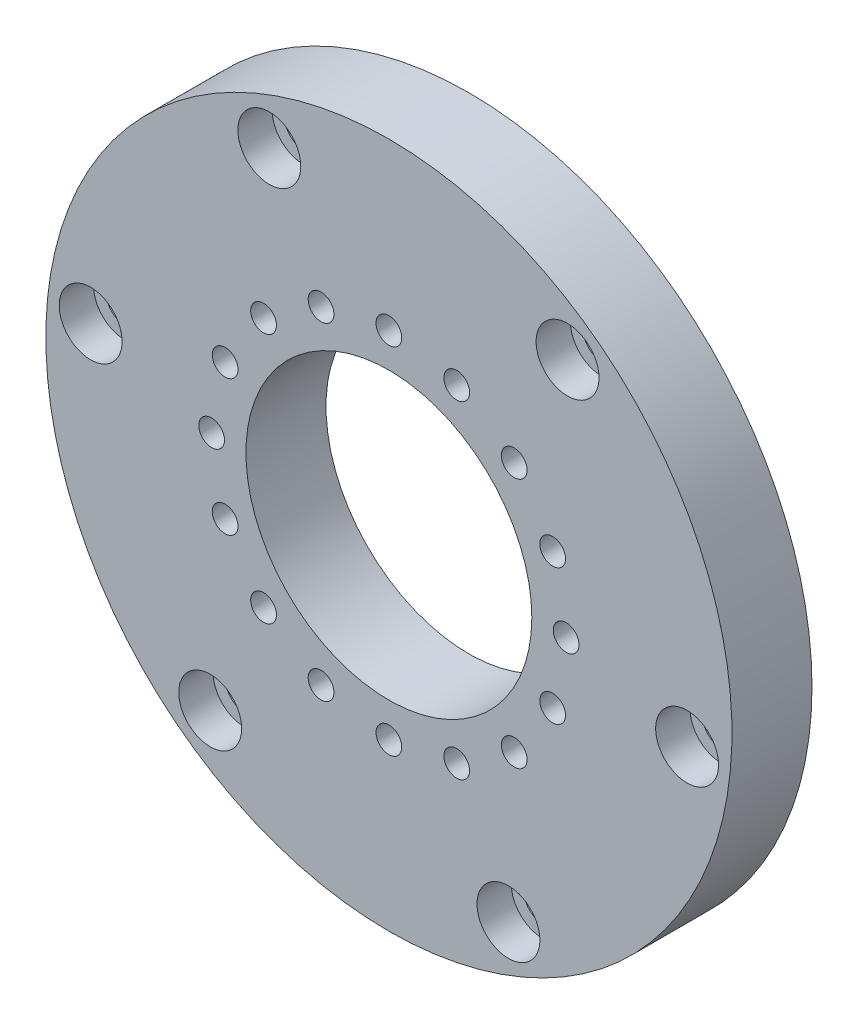
from build123d import *

# Parameters (mm, degrees)
SKETCH_2_R                   = 60
EXTRUDE_1_DEPTH              = 14
HOLE_WIZARD_M6_1_D           = 6.6
HOLE_WIZARD_M6_1_CBORE_D     = 11
HOLE_WIZARD_M6_1_CBORE_DEPTH = 6
PATTERN_CIRCULAR_1_COUNT     = 6
HOLE_WIZARD_M4_1_D           = 4.5
HOLE_WIZARD_M4_1_CBORE_D     = 8
HOLE_WIZARD_M4_1_CBORE_DEPTH = 4
SKETCH_9_R                   = 25
CUT_EXTRUDE_1_DEPTH          = 15


with BuildPart() as part:
    # 草圖2 → 填料-伸長1 (new body)
    with BuildSketch(Plane.XY):
        with Locations((0, -84)):
            Circle(SKETCH_2_R)
    extrude(amount=EXTRUDE_1_DEPTH)

    # M6 承窩頭蓋螺釘的柱孔1 (through all)
    with Locations(Plane.XY.offset(14)):
        with Locations((52.159798329, -89.96702927)):
            hole_wizard_m6_1 = CounterBoreHole(HOLE_WIZARD_M6_1_D / 2, HOLE_WIZARD_M6_1_CBORE_D / 2, HOLE_WIZARD_M6_1_CBORE_DEPTH)

    # 環狀複製排列1: M6 承窩頭蓋螺釘的柱孔1 ×6 about axis
    pattern_circular_1_axis = Axis((0, -84, 0), (0, 0, 1))
    for i in range(1, PATTERN_CIRCULAR_1_COUNT):
        add(hole_wizard_m6_1.rotate(pattern_circular_1_axis, i * 360 / PATTERN_CIRCULAR_1_COUNT), mode=Mode.SUBTRACT)

    # M4 承窩頭蓋螺釘的柱孔1 (through all)
    with Locations(Plane(origin=(0, 0, 0), x_dir=(-1, 0, 0), z_dir=(0, 0, -1))):
        with Locations((0, -53), (-11.863186403, -55.359734492), (-21.920310217, -62.079689783), (-28.640265508, -72.136813597), (-31, -84), (-28.640265508, -95.863186403), (-21.920310217, -105.920310217), (-11.863186403, -112.640265508), (0, -115), (11.863186403, -112.640265508), (21.920310217, -105.920310217), (28.640265508, -95.863186403), (31, -84), (28.640265508, -72.136813597), (21.920310217, -62.079689783), (11.863186403, -55.359734492)):
            CounterBoreHole(HOLE_WIZARD_M4_1_D / 2, HOLE_WIZARD_M4_1_CBORE_D / 2, HOLE_WIZARD_M4_1_CBORE_DEPTH)

    # 草圖9 → 除料-伸長1 (cut, through all)
    with BuildSketch(Plane.XY.offset(14)):
        with Locations((0, -84)):
            Circle(SKETCH_9_R)
    extrude(amount=-CUT_EXTRUDE_1_DEPTH, mode=Mode.SUBTRACT)


solid = part.part
